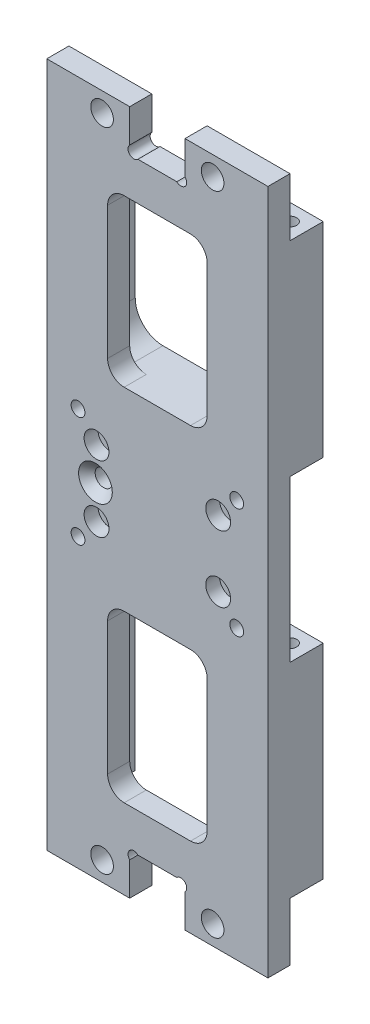
from build123d import *

# Parameters (mm, degrees)
SKETCH_1_R               = 2.05
SKETCH_1_R_2             = 1.05
SKETCH_1_R_3             = 1.55
SKETCH_1_R_4             = 1.25
EXTRUDE_1_DEPTH          = 4
EXTRUDE_START            = -4
EXTRUDE_2_DEPTH          = 6
SKETCH_4_R               = 1.05
CUT_EXTRUDE_2_DEPTH      = 11
SKETCH_5_R               = 1.2
CUT_EXTRUDE_3_DEPTH      = 114.5
FILLET_1_R               = 5
SKETCH_6_R               = 2.25
CUT_EXTRUDE_4_DEPTH      = 2.5
CHAMFER_1_SIZE           = 1.5
CUT_EXTRUDE_6_DEPTH      = 1
CUT_EXTRUDE_6_DEPTH_BACK = 11


with BuildPart() as part:
    # 草图1 → 凸台-拉伸1 (new body)
    with BuildSketch(Plane.XY):
        Polygon((20, -62), (5, -62), (5, -54.5), (-5, -54.5), (-5, -62), (-20, -62), (-20, 62), (-5, 62), (-5, 54.5), (5, 54.5), (5, 62), (20, 62), align=None)
        with Locations((10, 58.5)):
            Circle(SKETCH_1_R, mode=Mode.SUBTRACT)
        with Locations((-10, 58.5)):
            Circle(SKETCH_1_R, mode=Mode.SUBTRACT)
        with Locations((10, -58.5)):
            Circle(SKETCH_1_R, mode=Mode.SUBTRACT)
        with Locations((-10, -58.5)):
            Circle(SKETCH_1_R, mode=Mode.SUBTRACT)
        with Locations((-11, 6)):
            Circle(SKETCH_1_R_2, mode=Mode.SUBTRACT)
        with Locations((-11, -6)):
            Circle(SKETCH_1_R_2, mode=Mode.SUBTRACT)
        with Locations((11, -6)):
            Circle(SKETCH_1_R_2, mode=Mode.SUBTRACT)
        with Locations((11, 6)):
            Circle(SKETCH_1_R_2, mode=Mode.SUBTRACT)
        with Locations((-11.2, 0)):
            Circle(SKETCH_1_R_3, mode=Mode.SUBTRACT)
        with Locations((-14.35, -10)):
            Circle(SKETCH_1_R_4, mode=Mode.SUBTRACT)
        with Locations((-14.35, 10)):
            Circle(SKETCH_1_R_4, mode=Mode.SUBTRACT)
        with Locations((14.35, 10)):
            Circle(SKETCH_1_R_4, mode=Mode.SUBTRACT)
        with Locations((14.35, -10)):
            Circle(SKETCH_1_R_4, mode=Mode.SUBTRACT)
    extrude(amount=EXTRUDE_1_DEPTH)

    # 草图3 → 凸台-拉伸2 (add)
    with BuildSketch(Plane.XY.offset(4).offset(EXTRUDE_START)):
        Polygon((-20, 14.55), (20, 14.55), (20, 51.5), (14, 51.5), (14, 17.55), (-14, 17.55), (-14, 51.5), (-20, 51.5), align=None)
        Polygon((14, -17.55), (-14, -17.55), (-14, -51.5), (-20, -51.5), (-20, -14.55), (20, -14.55), (20, -51.5), (14, -51.5), align=None)
    extrude(amount=-EXTRUDE_2_DEPTH)

    # 草图4 → 切除-拉伸2 (cut, through all)
    with BuildSketch(Plane.XY.offset(4)):
        with Locations((-4.25753788, -55.24246212)):
            Circle(SKETCH_4_R)
        with Locations((4.25753788, -55.24246212)):
            Circle(SKETCH_4_R)
        with Locations((4.25753788, 55.24246212)):
            Circle(SKETCH_4_R)
        with Locations((-4.25753788, 55.24246212)):
            Circle(SKETCH_4_R)
    extrude(amount=-CUT_EXTRUDE_2_DEPTH, mode=Mode.SUBTRACT)

    # 草图5 → 切除-拉伸3 (cut, through all)
    with BuildSketch(Plane.XZ.offset(51.5)):
        with Locations((17, -3)):
            Circle(SKETCH_5_R)
        with Locations((-17, -3)):
            Circle(SKETCH_5_R)
    extrude(amount=-CUT_EXTRUDE_3_DEPTH, mode=Mode.SUBTRACT)

    # 圆角1
    fillet_1_edges = [part.edges().sort_by_distance(p)[0] for p in [
        (14, -17.55, -3),
        (-14, -17.55, -3),
        (-14, 17.55, -3),
        (14, 17.55, -3),
    ]]
    fillet(fillet_1_edges, radius=FILLET_1_R)

    # 草图6 → 切除-拉伸4 (cut)
    with BuildSketch(Plane.XY.offset(4)):
        with Locations((-11, -6)):
            Circle(SKETCH_6_R)
        with Locations((-11, 6)):
            Circle(SKETCH_6_R)
        with Locations((11, 6)):
            Circle(SKETCH_6_R)
        with Locations((11, -6)):
            Circle(SKETCH_6_R)
    extrude(amount=-CUT_EXTRUDE_4_DEPTH, mode=Mode.SUBTRACT)

    # 倒角1
    chamfer_1_edges = [part.edges().sort_by_distance(p)[0] for p in [
        (-12.75, 0, 4),
    ]]
    chamfer(chamfer_1_edges, length=CHAMFER_1_SIZE)

    # 草图8 → 切除-拉伸6 (cut, two sides)
    with BuildSketch(Plane.XY.offset(4)) as cut_extrude_6_sk:
        with BuildLine():
            Line((6, -17.55), (-6, -17.55))
            ThreePointArc((-6, -17.55), (-8.121320344, -18.428679656), (-9, -20.55))
            Line((-9, -20.55), (-9, -44.55))
            ThreePointArc((-9, -44.55), (-8.121320344, -46.671320344), (-6, -47.55))
            Line((-6, -47.55), (6, -47.55))
            ThreePointArc((6, -47.55), (8.121320344, -46.671320344), (9, -44.55))
            Line((9, -44.55), (9, -20.55))
            ThreePointArc((9, -20.55), (8.121320344, -18.428679656), (6, -17.55))
        make_face()
        with BuildLine():
            Line((-9, 20.55), (-9, 44.55))
            ThreePointArc((-9, 44.55), (-8.121320344, 46.671320344), (-6, 47.55))
            Line((-6, 47.55), (6, 47.55))
            ThreePointArc((6, 47.55), (8.121320344, 46.671320344), (9, 44.55))
            Line((9, 44.55), (9, 20.55))
            ThreePointArc((9, 20.55), (8.121320344, 18.428679656), (6, 17.55))
            Line((6, 17.55), (-6, 17.55))
            ThreePointArc((-6, 17.55), (-8.121320344, 18.428679656), (-9, 20.55))
        make_face()
    extrude(amount=CUT_EXTRUDE_6_DEPTH, mode=Mode.SUBTRACT)
    extrude(cut_extrude_6_sk.sketch, amount=-CUT_EXTRUDE_6_DEPTH_BACK, mode=Mode.SUBTRACT)


solid = part.part
